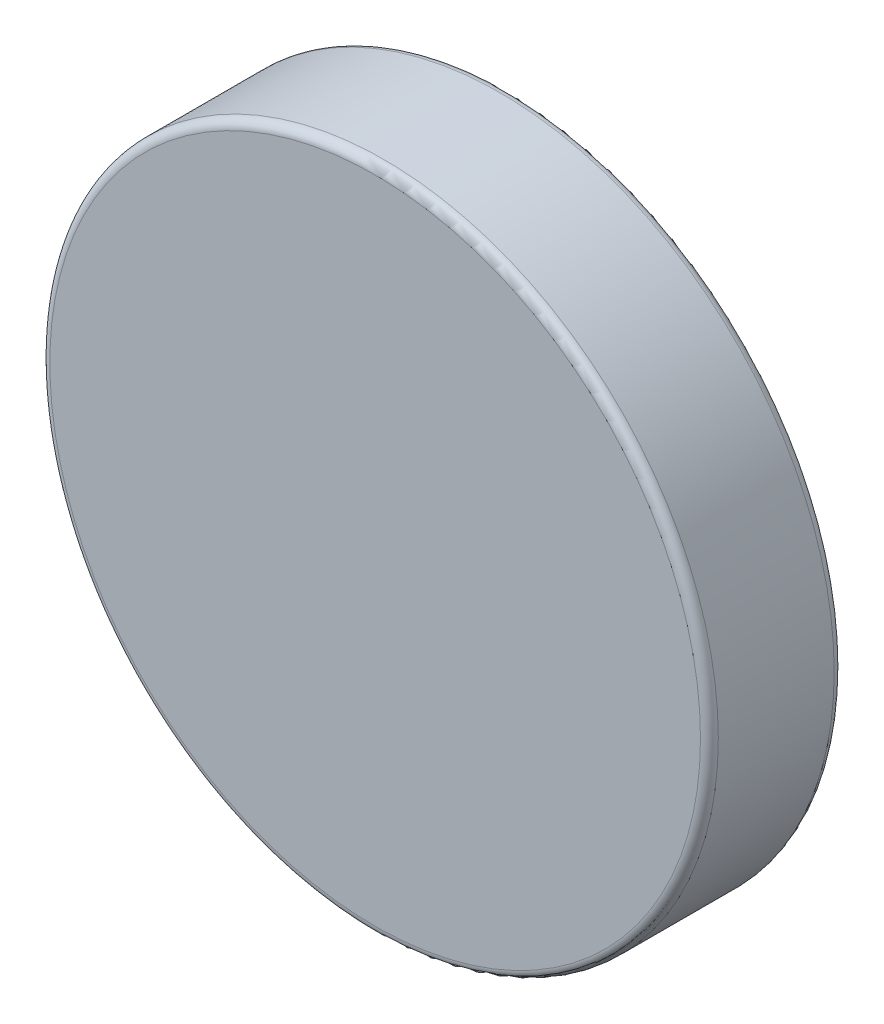
from build123d import *

# Parameters (mm, degrees)
SKETCH_1_R      = 7.5
EXTRUDE_1_DEPTH = 3
FILLET_1_R      = 0.2


with BuildPart() as part:
    # 草图1 → 凸台-拉伸1 (new body)
    with BuildSketch(Plane.XY):
        Circle(SKETCH_1_R)
    extrude(amount=EXTRUDE_1_DEPTH)

    # 圆角1
    fillet_1_edges = [part.edges().sort_by_distance(p)[0] for p in [
        (-7.5, 0, 0),
        (-7.5, 0, 3),
    ]]
    fillet(fillet_1_edges, radius=FILLET_1_R)


solid = part.part
